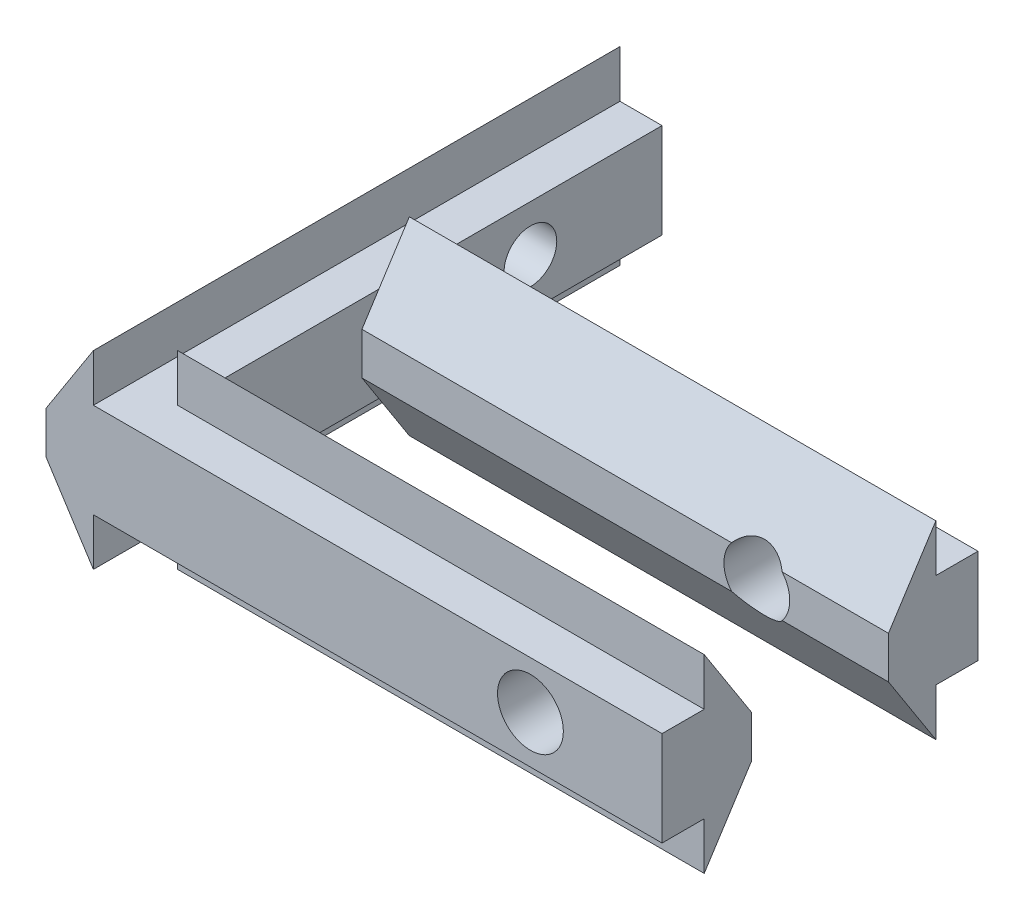
from build123d import *

# Parameters (mm, degrees)
BOSS_EXTRU_1_DEPTH      = 20
ESQUISSE1_R             = 1
ENL_V_MAT_EXTRU_1_DEPTH = 4.4
BOSS_EXTRU_2_DEPTH      = 20
ESQUISSE3_R             = 1.25
ENL_V_MAT_EXTRU_2_DEPTH = 21


with BuildPart() as part:
    # ProfileRainureEsquisse → Boss.-Extru.1 (new body)
    with BuildSketch(Plane.XY):
        Polygon((0, 0), (0, 1.6), (1.8, 4.4), (1.8, 2.6), (3.4, 2.6), (3.4, -1), (1.8, -1), (1.8, -2.8), align=None)
    extrude(amount=BOSS_EXTRU_1_DEPTH)

    # Esquisse1 → Enlèv. mat.-Extru.1 (cut, through all)
    with BuildSketch(Plane(origin=(3.4, 0, 0), x_dir=(0, 0, -1), z_dir=(1, 0, 0))):
        with Locations((-5, 0.8)):
            Circle(ESQUISSE1_R)
    extrude(amount=-ENL_V_MAT_EXTRU_1_DEPTH, mode=Mode.SUBTRACT)

    # Esquisse2 → Boss.-Extru.2 (add)
    with BuildSketch(Plane(origin=(3.4, 0, 0), x_dir=(0, 0, -1), z_dir=(1, 0, 0))):
        Polygon((-16.6, 0), (-16.6, 1.6), (-18.4, 4.4), (-18.4, 2.6), (-20, 2.6), (-20, -1), (-18.4, -1), (-18.4, -2.8), align=None)
        Polygon((-11.4, 1.6), (-11.4, 0), (-9.6, -2.8), (-9.6, -1), (-8, -1), (-8, 2.6), (-9.6, 2.6), (-9.6, 4.4), align=None)
    extrude(amount=BOSS_EXTRU_2_DEPTH)

    # Esquisse3 → Enlèv. mat.-Extru.2 (cut, through all)
    with BuildSketch(Plane.XY.offset(20)):
        with Locations((18.4, 0.8)):
            Circle(ESQUISSE3_R)
    extrude(amount=-ENL_V_MAT_EXTRU_2_DEPTH, mode=Mode.SUBTRACT)


solid = part.part
